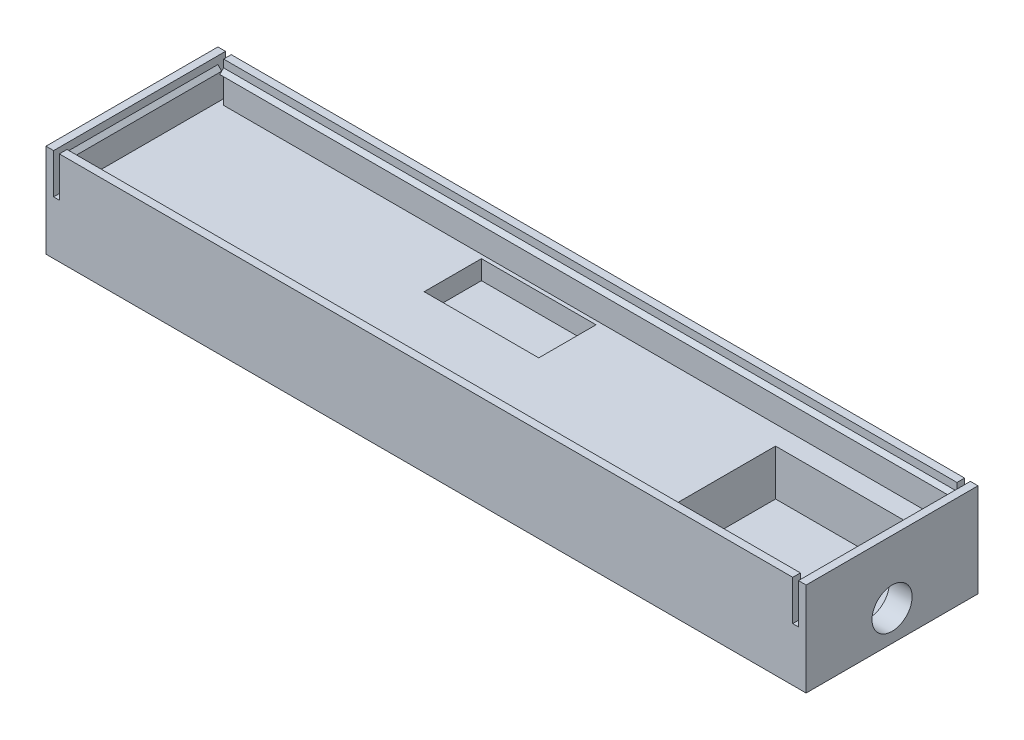
from build123d import *

# Parameters (mm, degrees)
SKETCH1_W           = 199
SKETCH1_H           = 45
BOSS_EXTRUDE1_DEPTH = 14
CUT_EXTRUDE1_DEPTH  = 12
CUT_EXTRUDE2_REACH  = 201
SKETCH3_R           = 5.25
SKETCH4_W           = 30
SKETCH4_H           = 15
CUT_EXTRUDE3_DEPTH  = 5
SKETCH5_W           = 199
SKETCH5_H           = 45
SKETCH5_W_2         = 195
SKETCH5_H_2         = 41
BOSS_EXTRUDE2_DEPTH = 10.5
SKETCH6_W           = 1.5
SKETCH6_H           = 2
CUT_EXTRUDE4_DEPTH  = 10.5
BOSS_EXTRUDE5_DEPTH = 41
BOSS_EXTRUDE6_DEPTH = 192
SKETCH9_R           = 3.5
CUT_EXTRUDE5_DEPTH  = 8


with BuildPart() as part:
    # Sketch1 → Boss-Extrude1 (new body)
    with BuildSketch(Plane(origin=(0, 0, 0), x_dir=(1, 0, 0), z_dir=(0, 1, 0))):
        Rectangle(SKETCH1_W, SKETCH1_H)
    extrude(amount=BOSS_EXTRUDE1_DEPTH)

    # Sketch2 → Cut-Extrude1 (cut)
    with BuildSketch(Plane(origin=(0, 14, 0), x_dir=(1, 0, 0), z_dir=(0, 1, 0))):
        Polygon((88.5, 10.5), (88.5, 15.5), (53.5, 15.5), (53.5, -15.5), (88.5, -15.5), (88.5, -10.5), (93.5, -10.5), (93.5, 10.5), align=None)
    extrude(amount=-CUT_EXTRUDE1_DEPTH, mode=Mode.SUBTRACT)

    # Sketch3 → Cut-Extrude2 (cut, up to next)
    with BuildSketch(Plane(origin=(99.5, 0, 0), x_dir=(0, 0, -1), z_dir=(1, 0, 0)), mode=Mode.PRIVATE) as cut_extrude2_sk1:
        with Locations((0, 8)):
            Circle(SKETCH3_R)
    cut_extrude2_tool1 = extrude(cut_extrude2_sk1.sketch, amount=-CUT_EXTRUDE2_REACH, mode=Mode.PRIVATE) & part.part
    add(cut_extrude2_tool1.solids().sort_by_distance((99.5, 8, 0))[0], mode=Mode.SUBTRACT)

    # Sketch4 → Cut-Extrude3 (cut)
    with BuildSketch(Plane(origin=(0, 14, 0), x_dir=(1, 0, 0), z_dir=(0, 1, 0))):
        with Locations((-12.5, 12)):
            Rectangle(SKETCH4_W, SKETCH4_H)
    extrude(amount=-CUT_EXTRUDE3_DEPTH, mode=Mode.SUBTRACT)

    # Sketch5 → Boss-Extrude2 (add)
    with BuildSketch(Plane(origin=(0, 14, 0), x_dir=(1, 0, 0), z_dir=(0, 1, 0))):
        Rectangle(SKETCH5_W, SKETCH5_H)
        Rectangle(SKETCH5_W_2, SKETCH5_H_2, mode=Mode.SUBTRACT)
    extrude(amount=BOSS_EXTRUDE2_DEPTH)

    # Sketch6 → Cut-Extrude4 (cut)
    with BuildSketch(Plane(origin=(0, 24.5, 0), x_dir=(1, 0, 0), z_dir=(0, 1, 0))):
        with Locations((-96.75, 21.5)):
            Rectangle(SKETCH6_W, SKETCH6_H)
        with Locations((96.75, 21.5)):
            Rectangle(SKETCH6_W, SKETCH6_H)
        with Locations((96.75, -21.5)):
            Rectangle(SKETCH6_W, SKETCH6_H)
        with Locations((-96.75, -21.5)):
            Rectangle(SKETCH6_W, SKETCH6_H)
    extrude(amount=-CUT_EXTRUDE4_DEPTH, mode=Mode.SUBTRACT)

    # Sketch7 → Boss-Extrude5 (add)
    with BuildSketch(Plane.XY.offset(-20.5)):
        Polygon((-97.5, 22.500142463), (-96.5, 21.500142463), (-97.5, 20.500142463), align=None)
        Polygon((97.5, 20.500142463), (97.5, 22.500142463), (96.5, 21.500142463), align=None)
    extrude(amount=BOSS_EXTRUDE5_DEPTH)

    # Sketch8 → Boss-Extrude6 (add)
    with BuildSketch(Plane(origin=(96, 0, 0), x_dir=(0, 0, -1), z_dir=(1, 0, 0))):
        Polygon((-20.5, 22.5), (-19.5, 21.5), (-20.5, 20.5), align=None)
        Polygon((20.5, 20.5), (20.5, 22.5), (19.5, 21.5), align=None)
    extrude(amount=-BOSS_EXTRUDE6_DEPTH)

    # Sketch9 → Cut-Extrude5 (cut)
    with BuildSketch(Plane.XZ):
        with Locations((-93.5, 16.5)):
            Circle(SKETCH9_R)
        with Locations((-93.5, -16.5)):
            Circle(SKETCH9_R)
        with Locations((93.5, -16.5)):
            Circle(SKETCH9_R)
        with Locations((93.5, 16.5)):
            Circle(SKETCH9_R)
    extrude(amount=-CUT_EXTRUDE5_DEPTH, mode=Mode.SUBTRACT)


solid = part.part
